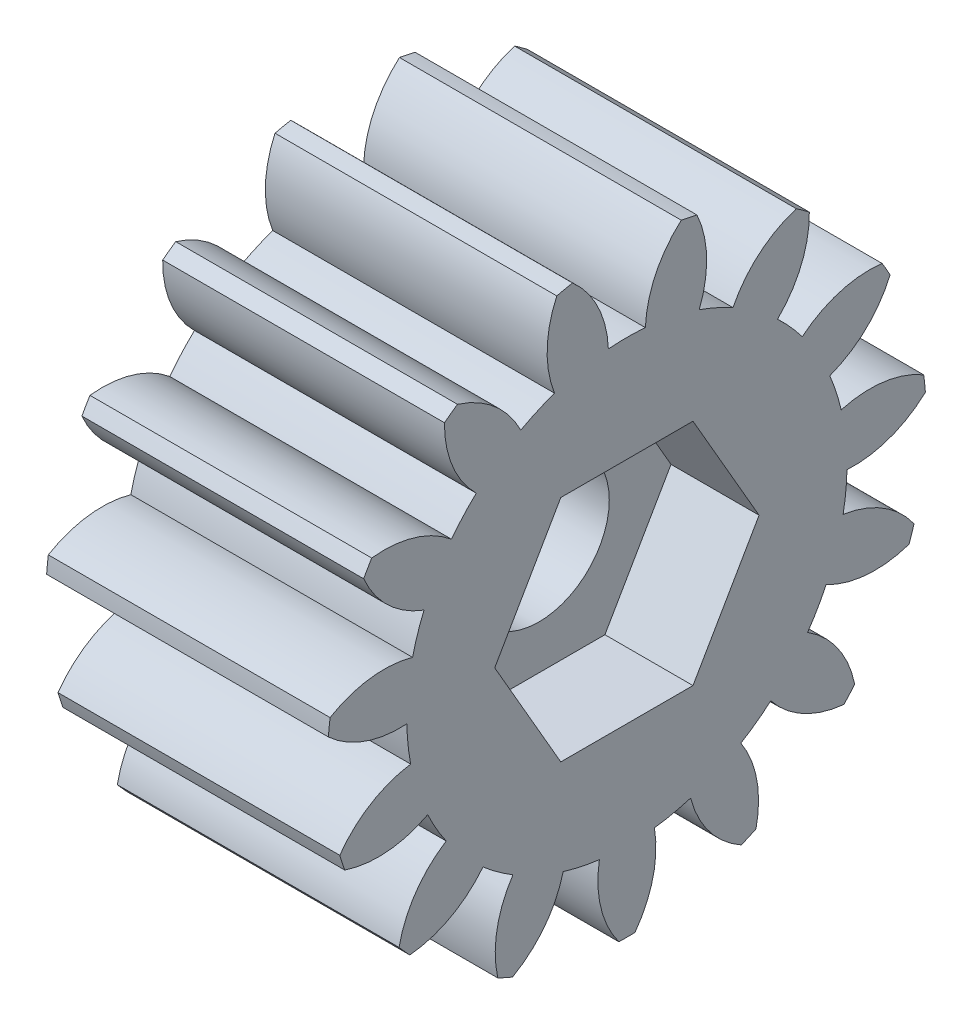
from build123d import *

# Parameters (mm, degrees)
BASPROSKE_W        = 16
BASPROSKE_H        = 17
TOOTHCUT_DEPTH     = 29.879058156
TEETHCUTS_COUNT    = 15
TEETHCUTS_ANGLE    = 336
BORSKE_R           = 4
BORE_DEPTH         = 50.0000508
CUT_EXTRUDE1_DEPTH = 5


with BuildPart() as part:
    # BasProSke → Base-Revolve (revolve)
    with BuildSketch(Plane(origin=(0, 0, 0), x_dir=(1, 0, 0), z_dir=(0, 1, 0)), mode=Mode.PRIVATE) as base_revolve_sk:
        with Locations((8, 8.5)):
            Rectangle(BASPROSKE_W, BASPROSKE_H)
    revolve(base_revolve_sk.sketch.rotate(Axis((-10, 0, 0), (1, 0, 0)), 180), axis=Axis((-10, 0, 0), (1, 0, 0)))

    # TooCutSke → ToothCut (cut, through all)
    with BuildSketch(Plane(origin=(0, 0, 0), x_dir=(0, 0, -1), z_dir=(1, 0, 0))):
        with BuildLine():
            ThreePointArc((1.050056448, 12.454813626), (0, 12.499), (-1.050056448, 12.454813626))
            ThreePointArc((-1.050056448, 12.454813626), (-1.638118106, 14.809604533), (-3.110934279, 16.73876737))
            ThreePointArc((-3.110934279, 16.73876737), (0, 17.0254), (3.110934279, 16.73876737))
            ThreePointArc((3.110934279, 16.73876737), (1.638118106, 14.809604533), (1.050056448, 12.454813626))
        make_face()
    toothcut = extrude(amount=TOOTHCUT_DEPTH, mode=Mode.SUBTRACT)

    # TeethCuts: ToothCut ×15 about axis
    teethcuts_axis = Axis((-10, 0, 0), (1, 0, 0))
    for i in range(1, TEETHCUTS_COUNT):
        add(toothcut.rotate(teethcuts_axis, i * TEETHCUTS_ANGLE / (TEETHCUTS_COUNT - 1)), mode=Mode.SUBTRACT)

    # BorSke → Bore (cut, symmetric)
    with BuildSketch(Plane(origin=(0, 0, 0), x_dir=(0, 0, -1), z_dir=(1, 0, 0))):
        with Locations(Location((0, 0, 0), (0, 0, 180))):
            Circle(BORSKE_R)
    extrude(amount=BORE_DEPTH, both=True, mode=Mode.SUBTRACT)

    # Sketch1 → Cut-Extrude1 (cut)
    with BuildSketch(Plane(origin=(16, 0, 0), x_dir=(0, 0, -1), z_dir=(1, 0, 0))):
        Polygon((-3.75277675, 6.5), (-7.505553499, 0), (-3.75277675, -6.5), (3.75277675, -6.5), (7.505553499, 0), (3.75277675, 6.5), align=None)
    extrude(amount=-CUT_EXTRUDE1_DEPTH, mode=Mode.SUBTRACT)


solid = part.part
